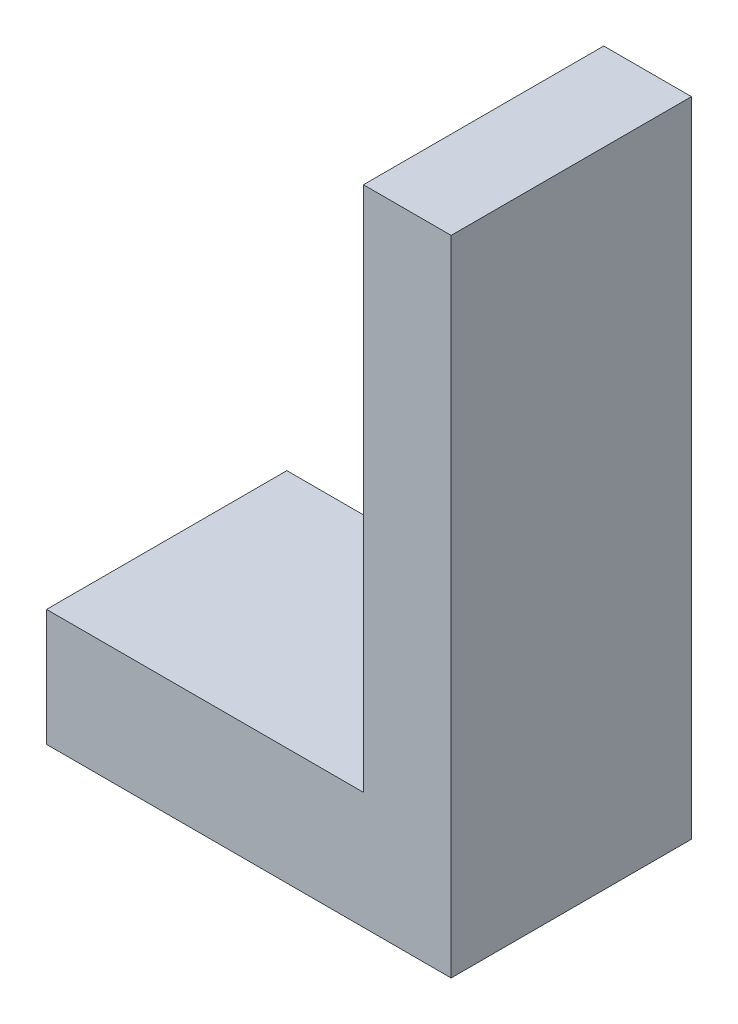
from build123d import *

# Parameters (mm, degrees)
SKETCH4_W            = 69.2
SKETCH4_H            = 45.8
SKETCH4_W_2          = 30
SKETCH4_H_2          = 30
BOSS_EXTRUDE11_DEPTH = 10
SKETCH9_W            = 69.2
SKETCH9_H            = 45.8
BOSS_EXTRUDE12_DEPTH = 10
SKETCH10_W           = 15
SKETCH10_H           = 45.8
BOSS_EXTRUDE13_DEPTH = 100
MOVE_FACE2_BY        = 4.7
MOVE_FACE3_BY        = 10
SKETCH11_W           = 25
SKETCH11_H           = 25
CUT_EXTRUDE1_DEPTH   = 10
MOVE_FACE4_BY        = 10


with BuildPart() as part:
    # Sketch4 → Boss-Extrude11 (new body)
    with BuildSketch(Plane(origin=(0, 0, 0), x_dir=(1, 0, 0), z_dir=(0, 1, 0))):
        Rectangle(SKETCH4_W, SKETCH4_H)
        Rectangle(SKETCH4_W_2, SKETCH4_H_2, mode=Mode.SUBTRACT)
    extrude(amount=BOSS_EXTRUDE11_DEPTH)

    # Sketch9 → Boss-Extrude12 (add)
    with BuildSketch(Plane(origin=(0, 10, 0), x_dir=(1, 0, 0), z_dir=(0, 1, 0))):
        Rectangle(SKETCH9_W, SKETCH9_H)
    extrude(amount=BOSS_EXTRUDE12_DEPTH)

    # Sketch10 → Boss-Extrude13 (add)
    with BuildSketch(Plane(origin=(0, 20, 0), x_dir=(1, 0, 0), z_dir=(0, 1, 0))):
        with Locations((27.1, 0)):
            Rectangle(SKETCH10_W, SKETCH10_H)
    extrude(amount=BOSS_EXTRUDE13_DEPTH)

    # Move Face2: a face moved inward by 4.7
    extrude(part.faces().sort_by_distance((0, 12, -22.9))[0], amount=MOVE_FACE2_BY, dir=(0, 0, 1), mode=Mode.SUBTRACT)

    # Move Face3: a face moved outward by 10.0
    extrude(part.faces().sort_by_distance((0, 10, 0))[0], amount=MOVE_FACE3_BY, dir=(0, -1, 0))

    # Sketch11 → Cut-Extrude1 (cut)
    with BuildSketch(Plane.XZ):
        with Locations((-4.99, 7.35)):
            Rectangle(SKETCH11_W, SKETCH11_H)
    extrude(amount=-CUT_EXTRUDE1_DEPTH, mode=Mode.SUBTRACT)

    # Move Face4: a face moved inward by 10.0
    extrude(part.faces().sort_by_distance((27.1, 120, 2.35))[0], amount=MOVE_FACE4_BY, dir=(0, -1, 0), mode=Mode.SUBTRACT)


solid = part.part
